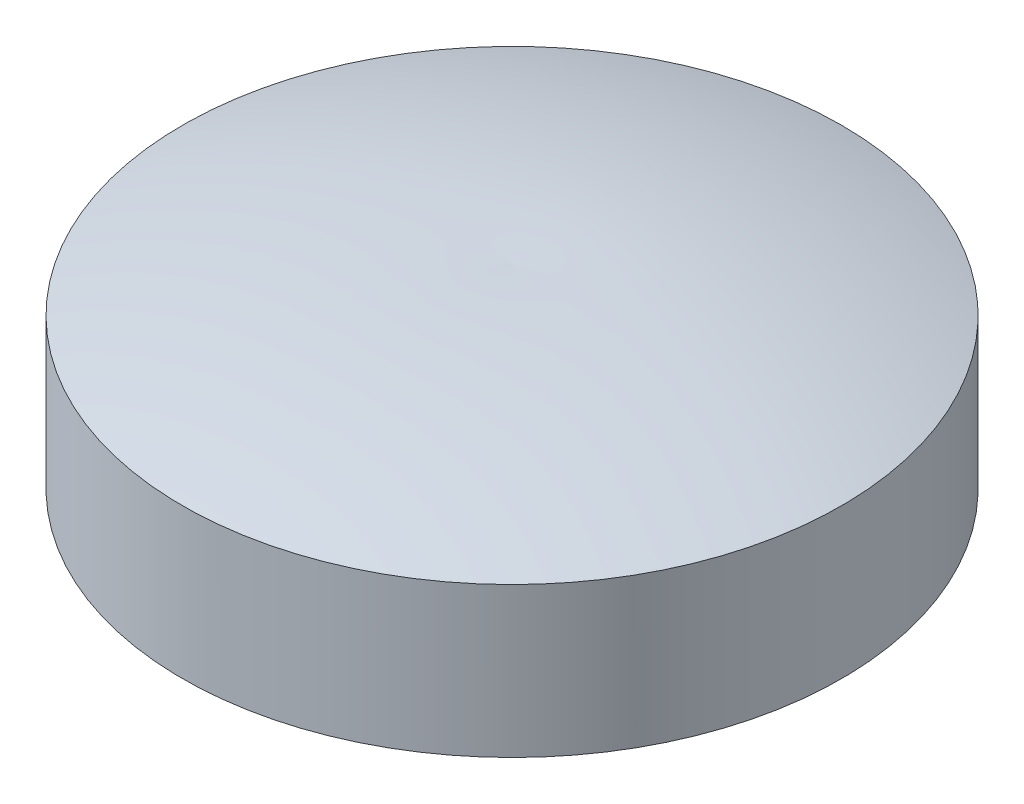
from build123d import *

# Parameters (mm, degrees)
CUT_EXTRUDE1_DEPTH = 5


with BuildPart() as part:
    # Sketch1 → Revolve1 (revolve)
    with BuildSketch(Plane.XY, mode=Mode.PRIVATE) as revolve1_sk:
        with BuildLine():
            Line((-0.097314546, 0.174365278), (21.902685454, 0.174365278))
            Line((21.902685454, 0.174365278), (21.902685454, 10.174365278))
            ThreePointArc((21.902685454, 10.174365278), (11.038548788, 12.670696395), (-0.097314546, 13.174365278))
            Line((-0.097314546, 13.174365278), (-0.097314546, 0.174365278))
        make_face()
    revolve(revolve1_sk.sketch.rotate(Axis((-0.097314546, 0.174365278, 0), (0, 1, 0)), 90), axis=Axis((-0.097314546, 0.174365278, 0), (0, 1, 0)))  # turned: the seam where the file's is

    # Sketch2 → Cut-Extrude1 (cut)
    with BuildSketch(Plane.XZ.offset(-0.174365278)):
        with BuildLine():
            ThreePointArc((-22.046178182, -1.499128104), (-20.597314546, 0), (-22.046178182, 1.499128104))
            ThreePointArc((-22.046178182, 1.499128104), (-22.097314546, 0), (-22.046178182, -1.499128104))
        make_face()
    extrude(amount=-CUT_EXTRUDE1_DEPTH, mode=Mode.SUBTRACT)


solid = part.part
